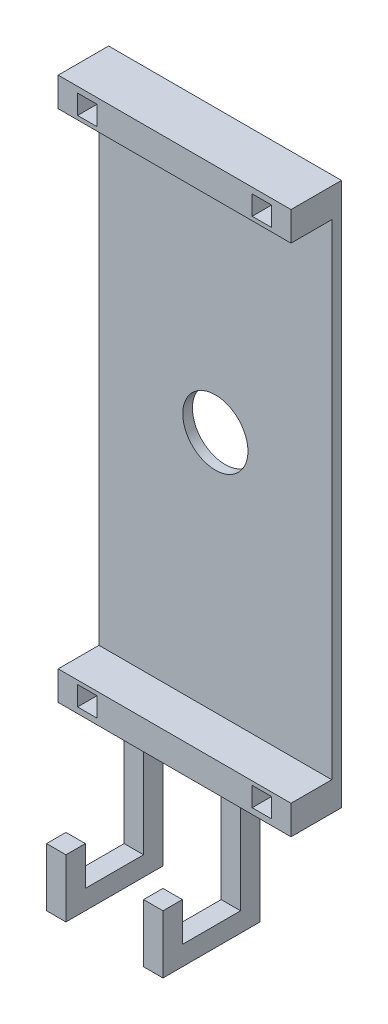
from build123d import *

# Parameters (mm, degrees)
SKETCH2_W           = 70
SKETCH2_H           = 140
BOSS_EXTRUDE1_DEPTH = 15
SKETCH7_W           = 70
SKETCH7_H           = 125
CUT_EXTRUDE4_DEPTH  = 12.5
SKETCH8_W           = 5
SKETCH8_H           = 5
CUT_EXTRUDE5_DEPTH  = 7
SKETCH6_R           = 8.4
CUT_EXTRUDE2_DEPTH  = 16
SKETCH9_OUTSIDE_W   = 103.448
SKETCH9_OUTSIDE_H   = 173.448
SKETCH9_OUTSIDE_W_2 = 60
SKETCH9_OUTSIDE_H_2 = 140
CUT_EXTRUDE6_DEPTH  = 15
SKETCH10_W          = 60
SKETCH10_H          = 2
CUT_EXTRUDE7_DEPTH  = 140
SKETCH11_W          = 5
SKETCH11_H          = 5
BOSS_EXTRUDE2_DEPTH = 30
SKETCH12_W          = 5
SKETCH12_H          = 5
BOSS_EXTRUDE3_DEPTH = 20
SKETCH13_W          = 5
SKETCH13_H          = 5
BOSS_EXTRUDE4_DEPTH = 10
SKETCH15_W          = 5
SKETCH15_H          = 5
BOSS_EXTRUDE5_DEPTH = 20
SKETCH16_W          = 5
SKETCH16_H          = 5
BOSS_EXTRUDE6_DEPTH = 10


with BuildPart() as part:
    # Sketch2 → Boss-Extrude1 (new body)
    with BuildSketch(Plane.XY):
        with Locations((35, 70)):
            Rectangle(SKETCH2_W, SKETCH2_H)
    extrude(amount=BOSS_EXTRUDE1_DEPTH)

    # Sketch7 → Cut-Extrude4 (cut)
    with BuildSketch(Plane.XY.offset(15)):
        with Locations((35, 70)):
            Rectangle(SKETCH7_W, SKETCH7_H)
    extrude(amount=-CUT_EXTRUDE4_DEPTH, mode=Mode.SUBTRACT)

    # Sketch8 → Cut-Extrude5 (cut)
    with BuildSketch(Plane.XY.offset(15)):
        with Locations((12.5, 136)):
            Rectangle(SKETCH8_W, SKETCH8_H)
        with Locations((57.5, 136)):
            Rectangle(SKETCH8_W, SKETCH8_H)
        with Locations((12.5, 4)):
            Rectangle(SKETCH8_W, SKETCH8_H)
        with Locations((57.5, 4)):
            Rectangle(SKETCH8_W, SKETCH8_H)
    extrude(amount=-CUT_EXTRUDE5_DEPTH, mode=Mode.SUBTRACT)

    # Sketch6 → Cut-Extrude2 (cut, through all)
    with BuildSketch(Plane(origin=(0, 0, 0), x_dir=(-1, 0, 0), z_dir=(0, 0, -1))):
        with Locations((-35, 70)):
            Circle(SKETCH6_R)
    extrude(amount=-CUT_EXTRUDE2_DEPTH, mode=Mode.SUBTRACT)

    # Sketch9 outside → Cut-Extrude6 (cut)
    with BuildSketch(Plane(origin=(0, 0, 0), x_dir=(-1, 0, 0), z_dir=(0, 0, -1))):
        with Locations((-35, 70)):
            Rectangle(SKETCH9_OUTSIDE_W, SKETCH9_OUTSIDE_H)
        with Locations((-35, 70)):
            Rectangle(SKETCH9_OUTSIDE_W_2, SKETCH9_OUTSIDE_H_2, mode=Mode.SUBTRACT)
    extrude(amount=-CUT_EXTRUDE6_DEPTH, mode=Mode.SUBTRACT)

    # Sketch10 → Cut-Extrude7 (cut)
    with BuildSketch(Plane(origin=(0, 140, 0), x_dir=(1, 0, 0), z_dir=(0, 1, 0))):
        with Locations((35, -14)):
            Rectangle(SKETCH10_W, SKETCH10_H)
    extrude(amount=-CUT_EXTRUDE7_DEPTH, mode=Mode.SUBTRACT)

    # Sketch11 → Boss-Extrude2 (add)
    with BuildSketch(Plane.XZ):
        with Locations((47.5, 8.5)):
            Rectangle(SKETCH11_W, SKETCH11_H)
        with Locations((22.5, 8.5)):
            Rectangle(SKETCH11_W, SKETCH11_H)
    extrude(amount=BOSS_EXTRUDE2_DEPTH)

    # Sketch12 → Boss-Extrude3 (add)
    with BuildSketch(Plane.XY.offset(11)):
        with Locations((22.5, -27.5)):
            Rectangle(SKETCH12_W, SKETCH12_H)
    extrude(amount=BOSS_EXTRUDE3_DEPTH)

    # Sketch13 → Boss-Extrude4 (add)
    with BuildSketch(Plane(origin=(0, -25, 0), x_dir=(1, 0, 0), z_dir=(0, 1, 0))):
        with Locations((22.5, -28.5)):
            Rectangle(SKETCH13_W, SKETCH13_H)
    extrude(amount=BOSS_EXTRUDE4_DEPTH)

    # Sketch15 → Boss-Extrude5 (add)
    with BuildSketch(Plane.XY.offset(11)):
        with Locations((47.5, -27.5)):
            Rectangle(SKETCH15_W, SKETCH15_H)
    extrude(amount=BOSS_EXTRUDE5_DEPTH)

    # Sketch16 → Boss-Extrude6 (add)
    with BuildSketch(Plane(origin=(0, -25, 0), x_dir=(1, 0, 0), z_dir=(0, 1, 0))):
        with Locations((47.5, -28.5)):
            Rectangle(SKETCH16_W, SKETCH16_H)
    extrude(amount=BOSS_EXTRUDE6_DEPTH)


solid = part.part
